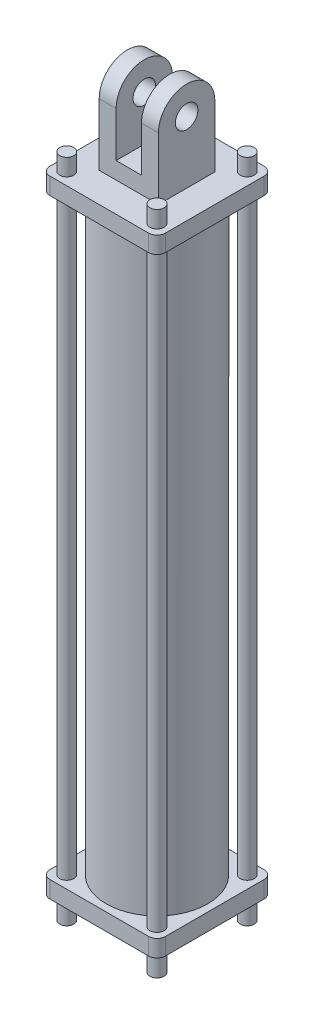
from build123d import *

# Parameters (mm, degrees)
SKETCH1_W                = 130.175
SKETCH1_H                = 130.175
BOSS_EXTRUDE1_DEPTH      = 19.05
CUT_EXTRUDE1_REACH       = 21.05
SKETCH2_R                = 7.9375
SKETCH3_R                = 12.7
BOSS_EXTRUDE2_DEPTH      = 33.3375
CUT_EXTRUDE2_REACH       = 98.837
SKETCH4_W                = 28.575
SKETCH4_H                = 82.55
SKETCH5_R                = 57.15
SKETCH5_R_2              = 50.8
BOSS_EXTRUDE3_DEPTH      = 666.75
FILLET1_R                = 9.525
SKETCH6_R                = 7.9375
BOSS_EXTRUDE4_DEPTH      = 19.05
CUT_EXTRUDE3_REACH       = 808.45
SKETCH7_R                = 25.4
SKETCH8_R                = 7.9375
BOSS_EXTRUDE5_DEPTH      = 19.05
BOSS_EXTRUDE5_DEPTH_BACK = 730.25


with BuildPart() as part:
    # Sketch1 → Boss-Extrude1 (new body)
    with BuildSketch(Plane(origin=(0, 0, 0), x_dir=(1, 0, 0), z_dir=(0, 1, 0))):
        Rectangle(SKETCH1_W, SKETCH1_H)
    extrude(amount=BOSS_EXTRUDE1_DEPTH)

    # Sketch2 → Cut-Extrude1 (cut, up to next)
    with BuildSketch(Plane(origin=(0, 19.05, 0), x_dir=(1, 0, 0), z_dir=(0, 1, 0)), mode=Mode.PRIVATE) as cut_extrude1_sk1:
        with Locations(Location((-50.8, 50.8, 0), (0, 0, 270))):  # turned: the seam where the file's is
            Circle(SKETCH2_R)
    cut_extrude1_tool1 = extrude(cut_extrude1_sk1.sketch, amount=-CUT_EXTRUDE1_REACH, mode=Mode.PRIVATE) & part.part
    add(cut_extrude1_tool1.solids().sort_by_distance((-50.8, 19.05, -50.8))[0], mode=Mode.SUBTRACT)
    # Sketch2 → Cut-Extrude1 (cut, up to next)
    with BuildSketch(Plane(origin=(0, 19.05, 0), x_dir=(1, 0, 0), z_dir=(0, 1, 0)), mode=Mode.PRIVATE) as cut_extrude1_sk2:
        with Locations(Location((50.8, 50.8, 0), (0, 0, 270))):  # turned: the seam where the file's is
            Circle(SKETCH2_R)
    cut_extrude1_tool2 = extrude(cut_extrude1_sk2.sketch, amount=-CUT_EXTRUDE1_REACH, mode=Mode.PRIVATE) & part.part
    add(cut_extrude1_tool2.solids().sort_by_distance((50.8, 19.05, -50.8))[0], mode=Mode.SUBTRACT)
    # Sketch2 → Cut-Extrude1 (cut, up to next)
    with BuildSketch(Plane(origin=(0, 19.05, 0), x_dir=(1, 0, 0), z_dir=(0, 1, 0)), mode=Mode.PRIVATE) as cut_extrude1_sk3:
        with Locations(Location((50.8, -50.8, 0), (0, 0, 270))):  # turned: the seam where the file's is
            Circle(SKETCH2_R)
    cut_extrude1_tool3 = extrude(cut_extrude1_sk3.sketch, amount=-CUT_EXTRUDE1_REACH, mode=Mode.PRIVATE) & part.part
    add(cut_extrude1_tool3.solids().sort_by_distance((50.8, 19.05, 50.8))[0], mode=Mode.SUBTRACT)
    # Sketch2 → Cut-Extrude1 (cut, up to next)
    with BuildSketch(Plane(origin=(0, 19.05, 0), x_dir=(1, 0, 0), z_dir=(0, 1, 0)), mode=Mode.PRIVATE) as cut_extrude1_sk4:
        with Locations(Location((-50.8, -50.8, 0), (0, 0, 270))):  # turned: the seam where the file's is
            Circle(SKETCH2_R)
    cut_extrude1_tool4 = extrude(cut_extrude1_sk4.sketch, amount=-CUT_EXTRUDE1_REACH, mode=Mode.PRIVATE) & part.part
    add(cut_extrude1_tool4.solids().sort_by_distance((-50.8, 19.05, 50.8))[0], mode=Mode.SUBTRACT)

    # Sketch3 → Boss-Extrude2 (add, symmetric)
    with BuildSketch(Plane(origin=(0, 0, 0), x_dir=(0, 0, -1), z_dir=(1, 0, 0))):
        with BuildLine():
            Line((-31.75, 19.05), (-31.75, 88.9))
            ThreePointArc((-31.75, 88.9), (0, 120.65), (31.75, 88.9))
            Line((31.75, 88.9), (31.75, 19.05))
            Line((31.75, 19.05), (-31.75, 19.05))
        make_face()
        with Locations((0, 88.9)):
            Circle(SKETCH3_R, mode=Mode.SUBTRACT)
    extrude(amount=BOSS_EXTRUDE2_DEPTH, both=True)

    # Sketch4 → Cut-Extrude2 (cut, up to next)
    with BuildSketch(Plane.XY.offset(31.75), mode=Mode.PRIVATE) as cut_extrude2_sk1:
        with Locations((0, 79.375)):
            Rectangle(SKETCH4_W, SKETCH4_H)
    cut_extrude2_tool1 = extrude(cut_extrude2_sk1.sketch, amount=-CUT_EXTRUDE2_REACH, mode=Mode.PRIVATE) & part.part
    add(cut_extrude2_tool1.solids().sort_by_distance((0, 79.375, 31.75))[0], mode=Mode.SUBTRACT)

    # Sketch5 → Boss-Extrude3 (add)
    with BuildSketch(Plane.XZ):
        with Locations(Location((0, 0, 0), (0, 0, 90))):  # turned: the seam where the file's is
            Circle(SKETCH5_R)
        with Locations(Location((0, 0, 0), (0, 0, 270))):  # turned: the seam where the file's is
            Circle(SKETCH5_R_2, mode=Mode.SUBTRACT)
    extrude(amount=BOSS_EXTRUDE3_DEPTH)

    # Fillet1
    fillet1_edges = [part.edges().sort_by_distance(p)[0] for p in [
        (65.0875, 9.525, 65.0875),
        (-65.0875, 9.525, 65.0875),
        (-65.0875, 9.525, -65.0875),
        (65.0875, 9.525, -65.0875),
    ]]
    fillet(fillet1_edges, radius=FILLET1_R)

    # Sketch6 → Boss-Extrude4 (add)
    with BuildSketch(Plane.XZ.offset(666.75)):
        with BuildLine():
            Line((-65.0875, 55.5625), (-65.0875, -55.5625))
            ThreePointArc((-65.0875, -55.5625), (-62.297692091, -62.297692091), (-55.5625, -65.0875))
            Line((-55.5625, -65.0875), (55.5625, -65.0875))
            ThreePointArc((55.5625, -65.0875), (62.297692091, -62.297692091), (65.0875, -55.5625))
            Line((65.0875, -55.5625), (65.0875, 55.5625))
            ThreePointArc((65.0875, 55.5625), (62.297692091, 62.297692091), (55.5625, 65.0875))
            Line((55.5625, 65.0875), (-55.5625, 65.0875))
            ThreePointArc((-55.5625, 65.0875), (-62.297692091, 62.297692091), (-65.0875, 55.5625))
        make_face()
        with Locations(Location((-50.8, 50.8, 0), (0, 0, 90))):  # turned: the seam where the file's is
            Circle(SKETCH6_R, mode=Mode.SUBTRACT)
        with Locations(Location((50.8, 50.8, 0), (0, 0, 90))):  # turned: the seam where the file's is
            Circle(SKETCH6_R, mode=Mode.SUBTRACT)
        with Locations(Location((50.8, -50.8, 0), (0, 0, 90))):  # turned: the seam where the file's is
            Circle(SKETCH6_R, mode=Mode.SUBTRACT)
        with Locations(Location((-50.8, -50.8, 0), (0, 0, 90))):  # turned: the seam where the file's is
            Circle(SKETCH6_R, mode=Mode.SUBTRACT)
    extrude(amount=BOSS_EXTRUDE4_DEPTH)

    # Sketch7 → Cut-Extrude3 (cut, up to next)
    with BuildSketch(Plane.XZ.offset(685.8), mode=Mode.PRIVATE) as cut_extrude3_sk1:
        with Locations(Location((0, 0, 0), (0, 0, 270))):  # turned: the seam where the file's is
            Circle(SKETCH7_R)
    cut_extrude3_tool1 = extrude(cut_extrude3_sk1.sketch, amount=-CUT_EXTRUDE3_REACH, mode=Mode.PRIVATE) & part.part
    add(cut_extrude3_tool1.solids().sort_by_distance((0, -685.8, 0))[0], mode=Mode.SUBTRACT)

    # Sketch8 → Boss-Extrude5 (add, two sides)
    with BuildSketch(Plane(origin=(0, 19.05, 0), x_dir=(1, 0, 0), z_dir=(0, 1, 0))) as boss_extrude5_sk:
        with Locations(Location((-50.8, 50.8, 0), (0, 0, 270))):  # turned: the seam where the file's is
            Circle(SKETCH8_R)
        with Locations(Location((50.8, 50.8, 0), (0, 0, 270))):  # turned: the seam where the file's is
            Circle(SKETCH8_R)
        with Locations(Location((50.8, -50.8, 0), (0, 0, 270))):  # turned: the seam where the file's is
            Circle(SKETCH8_R)
        with Locations(Location((-50.8, -50.8, 0), (0, 0, 270))):  # turned: the seam where the file's is
            Circle(SKETCH8_R)
    extrude(amount=BOSS_EXTRUDE5_DEPTH)
    extrude(boss_extrude5_sk.sketch, amount=-BOSS_EXTRUDE5_DEPTH_BACK)


solid = part.part
